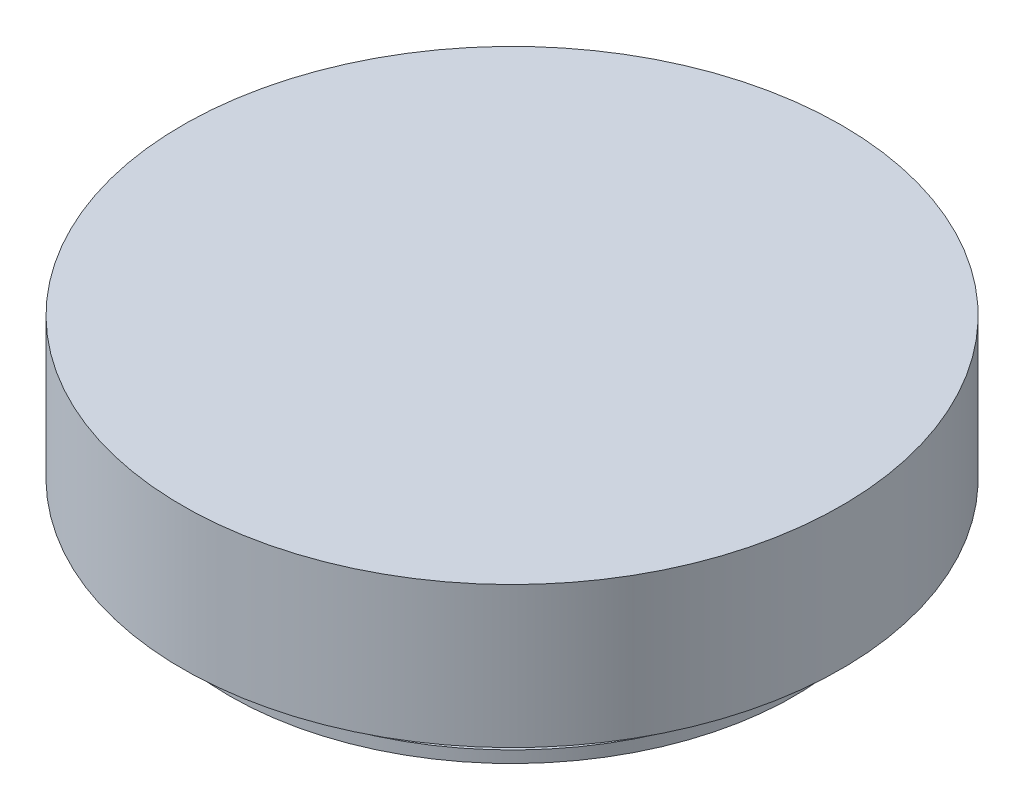
from build123d import *


with BuildPart() as part:
    # Sketch1 → Revolve1 (revolve)
    with BuildSketch(Plane.XY):
        Polygon((-38.1, 0), (0, 0), (0, 25.4), (-44.45, 25.4), (-44.45, 6.35), (-38.1, 6.35), (-38.1, 4.3307), (-36.068, 4.3307), (-36.068, 1.5875), (-38.1, 1.5875), align=None)
    revolve(axis=Axis((0, 0, 0), (0, 1, 0)))


solid = part.part
